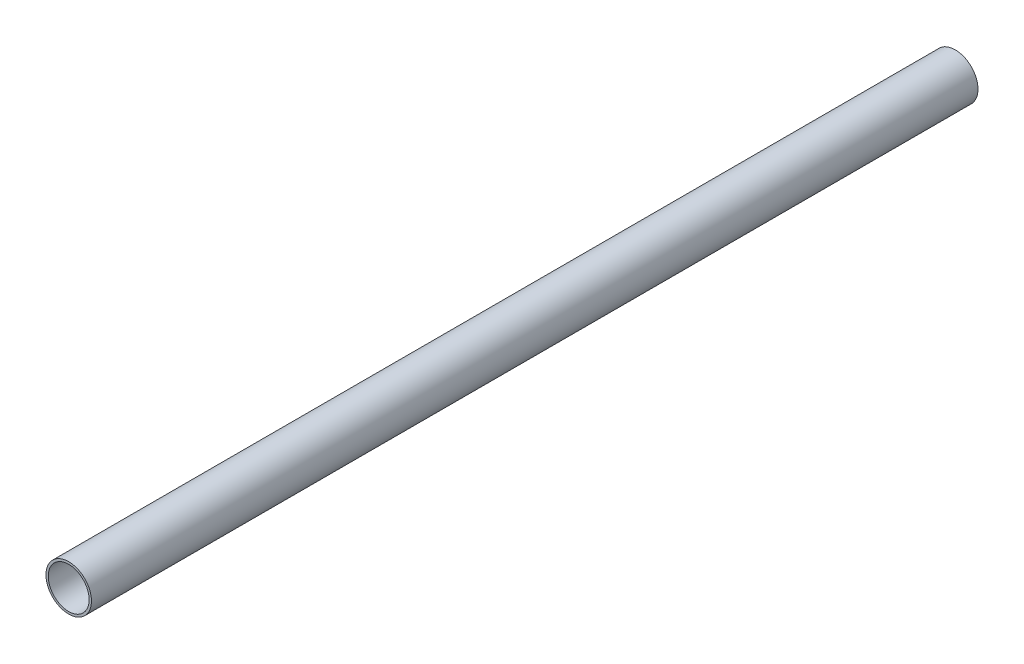
from build123d import *

# Parameters (mm, degrees)
SKETCH_1_R      = 5
SKETCH_1_R_2    = 4.5
EXTRUDE_1_DEPTH = 97.5


with BuildPart() as part:
    # Эскиз1 → Бобышка-Вытянуть1 (new body, symmetric)
    with BuildSketch(Plane.XY):
        Circle(SKETCH_1_R)
        Circle(SKETCH_1_R_2, mode=Mode.SUBTRACT)
    extrude(amount=EXTRUDE_1_DEPTH, both=True)


solid = part.part
